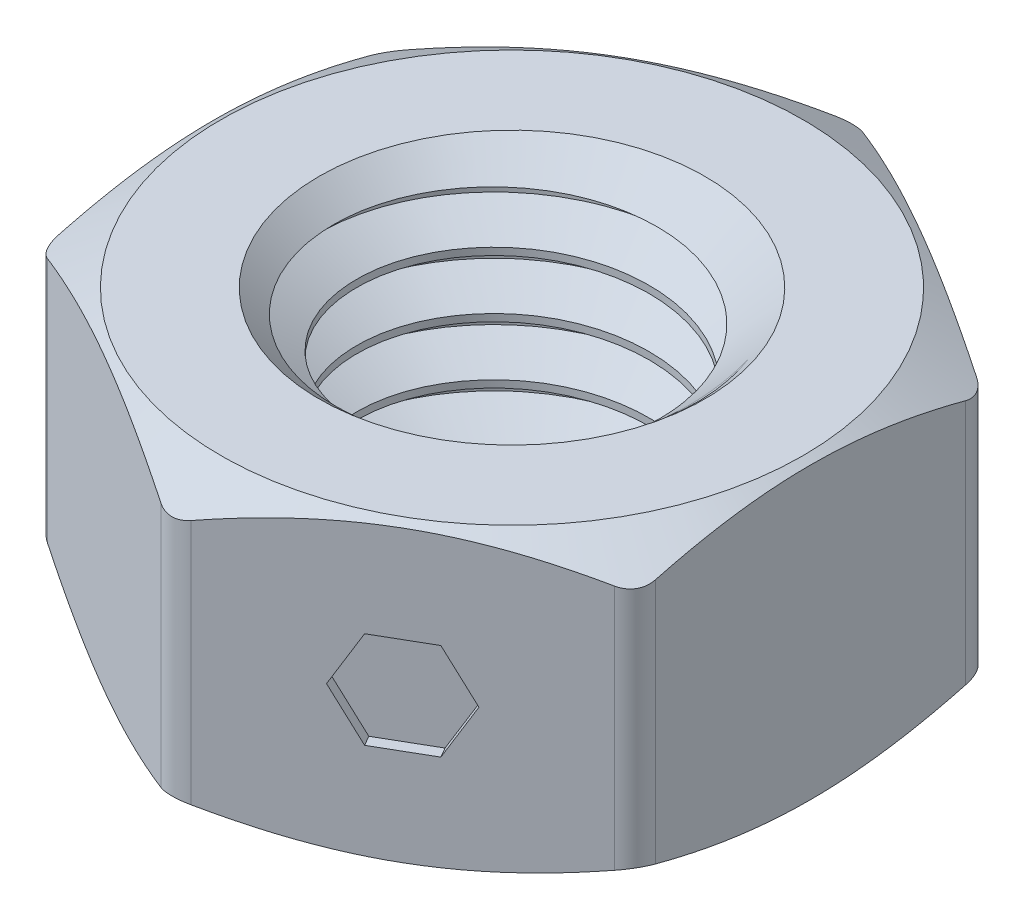
from build123d import *

# Parameters (mm, degrees)
SKETCH2_R                = 4
BOSS_EXTRUDE1_DEPTH      = 3.25
BOSS_EXTRUDE1_DEPTH_BACK = 3.25
FILLET1_R                = 0.65
CUT_EXTRUDE2_DEPTH       = 0.25
SKETCH6_W                = 4
SKETCH6_H                = 6.5
CUT_SWEEP1_PITCH         = 1.25
CUT_SWEEP1_HEIGHT        = 7.75
CUT_SWEEP1_RADIUS        = 4
CUT_SWEEP1_START_ANGLE   = 90
SKETCH10_R               = 4.2
BOSS_EXTRUDE2_DEPTH      = 6.5


with BuildPart() as part:
    # Sketch2 → Boss-Extrude1 (new, two sides)
    with BuildSketch(Plane(origin=(0, 0, 0), x_dir=(1, 0, 0), z_dir=(0, 1, 0))) as boss_extrude1_sk:
        Polygon((0, 7.505553499), (-6.5, 3.75277675), (-6.5, -3.75277675), (0, -7.505553499), (6.5, -3.75277675), (6.5, 3.75277675), align=None)
        with Locations(Location((0, 0, 0), (0, 0, 90))):
            Circle(SKETCH2_R, mode=Mode.SUBTRACT)
    extrude(amount=BOSS_EXTRUDE1_DEPTH)
    extrude(boss_extrude1_sk.sketch, amount=-BOSS_EXTRUDE1_DEPTH_BACK)

    # Fillet1
    fillet1_edges = [part.edges().sort_by_distance(p)[0] for p in [
        (6.5, 0, -3.75277675),
        (6.5, 0, 3.75277675),
        (0, 0, 7.505553499),
        (-6.5, 0, 3.75277675),
        (-6.5, 0, -3.75277675),
        (0, 0, -7.505553499),
    ]]
    fillet(fillet1_edges, radius=FILLET1_R)

    # Sketch3 → Cut-Revolve2 (revolve, cut)
    with BuildSketch(Plane(origin=(0, 0, 0), x_dir=(0, 0, -1), z_dir=(1, 0, 0)), mode=Mode.PRIVATE) as cut_revolve2_sk:
        Polygon((6.3375, -3.25), (7.505553499, -2.575623998), (7.505553499, -3.25), align=None)
        Polygon((4, 3.25), (4, 3.05), (4.2, 3.25), align=None)
        Polygon((4, -3.25), (4, -3.05), (4.2, -3.25), align=None)
        Polygon((6.3375, 3.25), (7.505553499, 2.575623998), (7.505553499, 3.25), align=None)
    revolve(cut_revolve2_sk.sketch.rotate(Axis((0, -3.25, 0), (0, 1, 0)), 270), axis=Axis((0, -3.25, 0), (0, 1, 0)), mode=Mode.SUBTRACT)

    # Sketch12 → Cut-Extrude2 (cut)
    with BuildSketch(Plane(origin=(3.25, 0, 5.629165125), x_dir=(0.8660254037844384, 0, -0.5000000000000006), z_dir=(0.5000000000000006, 0, 0.8660254037844385))):
        Polygon((-1.214814445, 0), (-0.607407223, -1.05206017), (0.607407223, -1.05206017), (1.214814445, 0), (0.607407223, 1.05206017), (-0.607407223, 1.05206017), align=None)
    extrude(amount=-CUT_EXTRUDE2_DEPTH, mode=Mode.SUBTRACT)

    # Sketch10 → Boss-Extrude2 (add)
    with BuildSketch(Plane.XZ.offset(3.25)):
        Circle(SKETCH10_R)
    extrude(amount=-BOSS_EXTRUDE2_DEPTH)


with BuildPart() as body_2:
    # Sketch6 → Revolve2 (revolve)
    with BuildSketch(Plane.XY, mode=Mode.PRIVATE) as revolve2_sk:
        with Locations((2, 0)):
            Rectangle(SKETCH6_W, SKETCH6_H)
    revolve(revolve2_sk.sketch.rotate(Axis((0, -3.25, 0), (0, 1, 0)), 90), axis=Axis((0, -3.25, 0), (0, 1, 0)))

    # Cut-Sweep1: sweep along a helix
    with BuildLine() as cut_sweep1_path:
        add(Helix(CUT_SWEEP1_PITCH, CUT_SWEEP1_HEIGHT, CUT_SWEEP1_RADIUS, center=(0, -3.25, 0), direction=(0, 1, 0), mode=Mode.PRIVATE).rotate(Axis((0, -3.25, 0), (0, 1, 0)), CUT_SWEEP1_START_ANGLE))
    # Sketch8 → Cut-Sweep1 (sweep, cut)
    with BuildSketch(Plane.XY):
        Polygon((3.188101184, -3.71875), (3.188101184, -3.875), (4.067658235, -4.3828125), (4.135316469, -3.171875), align=None)
    sweep(path=cut_sweep1_path.line, is_frenet=True, mode=Mode.SUBTRACT)

    # Sketch9 → Revolve3 (revolve)
    with BuildSketch(Plane.XY, mode=Mode.PRIVATE) as revolve3_sk:
        Polygon((0, 0.75), (0, -3.25), (4, -3.25), (4.2, -3.25), (0, 0.95), align=None)
    revolve(revolve3_sk.sketch.rotate(Axis((0, 0.75, 0), (0, -1, 0)), 347.19368346), axis=Axis((0, 0.75, 0), (0, -1, 0)))

    # Sketch11 → Revolve4 (revolve)
    with BuildSketch(Plane.XY, mode=Mode.PRIVATE) as revolve4_sk:
        Polygon((0, 3.25), (0, -0.4375), (4.2, 3.25), align=None)
    revolve(revolve4_sk.sketch.rotate(Axis((0, 3.25, 0), (0, -1, 0)), 347.19368346), axis=Axis((0, 3.25, 0), (0, -1, 0)))


with BuildPart() as part_1:
    add(part.part)

    # Combine1: cut body 2
    add(body_2.part, mode=Mode.SUBTRACT)


solid = part_1.part
